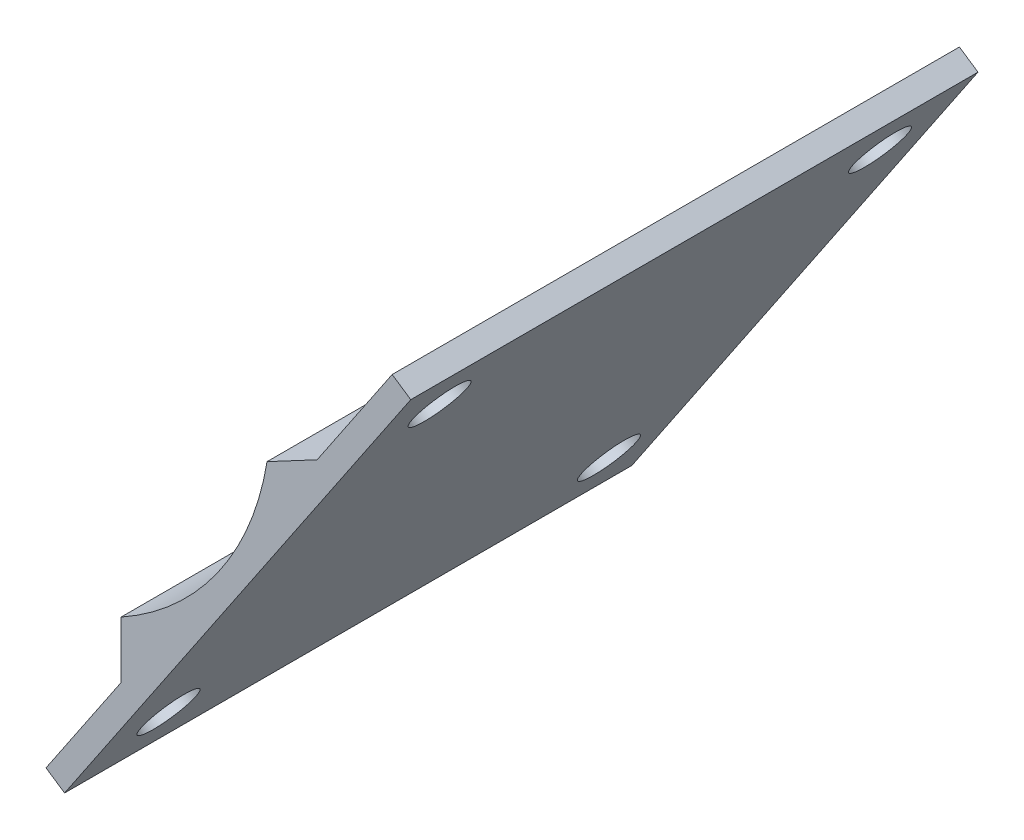
from build123d import *

# Parameters (mm, degrees)
BOSS_EXTRUDE1_DEPTH = 38
SKETCH2_R           = 1.85
CUT_EXTRUDE1_DEPTH  = 21.73151986


with BuildPart() as part:
    # Sketch1 → Boss-Extrude1 (new body)
    with BuildSketch(Plane.XY):
        with BuildLine():
            Line((19.245374747, -3.140947442), (22.599041108, -1.357255436))
            Line((22.599041108, -1.357255436), (27.628159729, 6.106521483))
            Line((27.628159729, 6.106521483), (28.872122548, 5.268335046))
            Line((28.872122548, 5.268335046), (5.682297797, -29.147969636))
            Line((5.682297797, -29.147969636), (4.438334977, -28.309783199))
            Line((4.438334977, -28.309783199), (9.467453598, -20.84600628))
            Line((9.467453598, -20.84600628), (9.467453598, -17.047501939))
            ThreePointArc((9.467453598, -17.047501939), (15.951636041, -11.21585073), (19.245374747, -3.140947442))
        make_face()
    extrude(amount=BOSS_EXTRUDE1_DEPTH)

    # Sketch2 → Cut-Extrude1 (cut, through all)
    with BuildSketch(Plane(origin=(16.171516658, -10.896423679, 0), x_dir=(0, 0, 1), z_dir=(-0.829308547, 0.558790958, 0))):
        with Locations((4.05, 16.002556295)):
            Circle(SKETCH2_R)
        with Locations((33.55, 16.002556295)):
            Circle(SKETCH2_R)
        with Locations((4.05, -16.497443705)):
            Circle(SKETCH2_R)
        with Locations((33.55, -16.497443705)):
            Circle(SKETCH2_R)
    extrude(amount=-CUT_EXTRUDE1_DEPTH, mode=Mode.SUBTRACT)


solid = part.part
